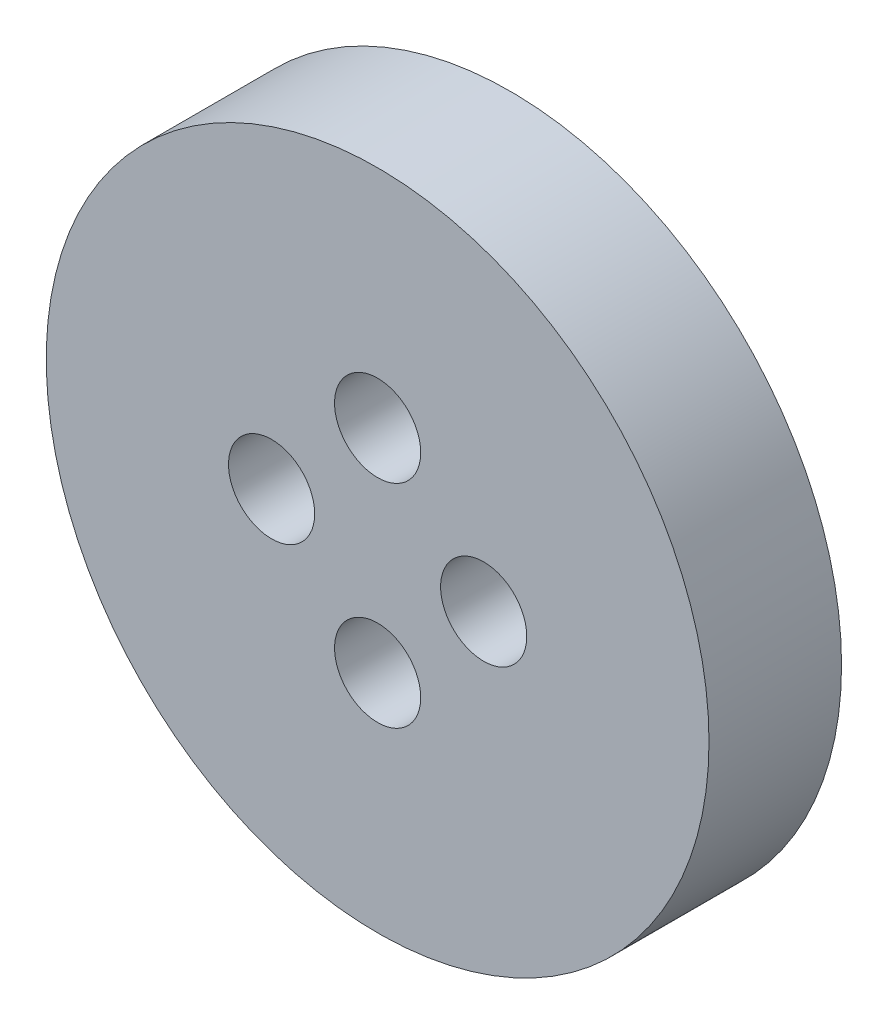
from build123d import *

# Parameters (mm, degrees)
SKETCH_1_R          = 25
SKETCH_1_R_2        = 1.75
EXTRUDE_1_DEPTH     = 10
SKETCH_2_R          = 3.25
CUT_EXTRUDE_1_DEPTH = 5


with BuildPart() as part:
    # ｽｹｯﾁ1 → ﾎﾞｽ - 押し出し1 (new body)
    with BuildSketch(Plane.XY):
        Circle(SKETCH_1_R)
        with Locations((8, 0)):
            Circle(SKETCH_1_R_2, mode=Mode.SUBTRACT)
        with Locations((0, -8)):
            Circle(SKETCH_1_R_2, mode=Mode.SUBTRACT)
        with Locations((-8, 0)):
            Circle(SKETCH_1_R_2, mode=Mode.SUBTRACT)
        with Locations((0, 8)):
            Circle(SKETCH_1_R_2, mode=Mode.SUBTRACT)
    extrude(amount=EXTRUDE_1_DEPTH)

    # ｽｹｯﾁ2 → ｶｯﾄ - 押し出し1 (cut)
    with BuildSketch(Plane.XY.offset(10)):
        with Locations((0, 8)):
            Circle(SKETCH_2_R)
        with Locations((8, 0)):
            Circle(SKETCH_2_R)
        with Locations((0, -8)):
            Circle(SKETCH_2_R)
        with Locations((-8, 0)):
            Circle(SKETCH_2_R)
    extrude(amount=-CUT_EXTRUDE_1_DEPTH, mode=Mode.SUBTRACT)


solid = part.part
